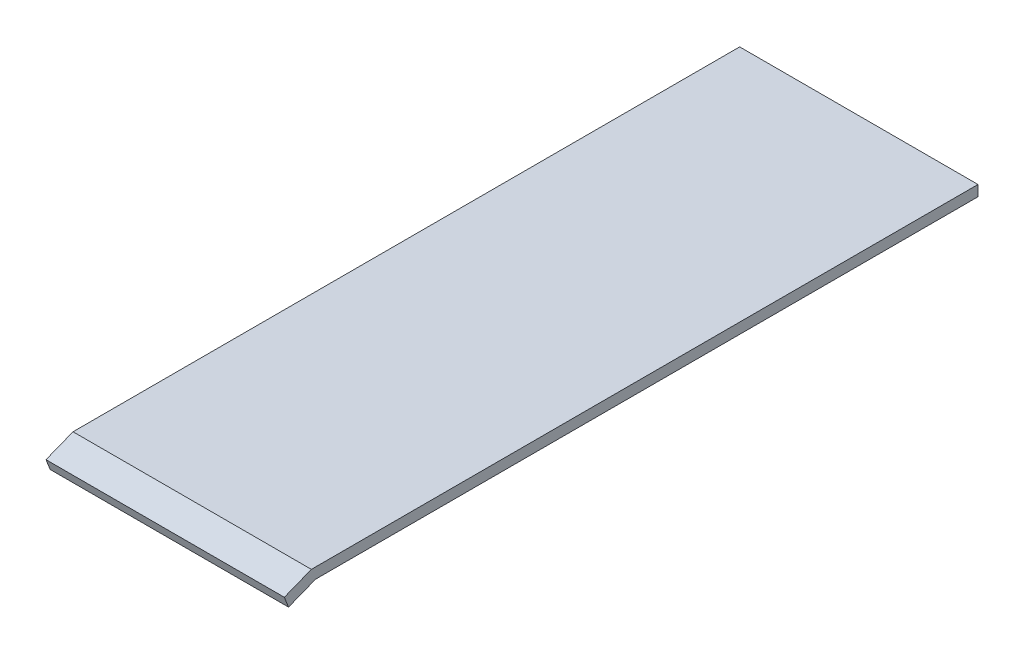
from build123d import *

# Parameters (mm, degrees)
SKETCH1_W                = 6.35
SKETCH1_H                = 6.35
BOSS_EXTRUDE1_DEPTH      = 5.08
BOSS_EXTRUDE2_DEPTH      = 14.850000018
BOSS_EXTRUDE2_DEPTH_BACK = 14.850000018


with BuildPart() as part:
    # Sketch1 → Boss-Extrude1 (new body)
    with BuildSketch(Plane(origin=(0, 0, 0), x_dir=(1, 0, 0), z_dir=(0, 1, 0))):
        Rectangle(SKETCH1_W, SKETCH1_H)
    extrude(amount=BOSS_EXTRUDE1_DEPTH)

    # Sketch2 → Boss-Extrude2 (add, two sides)
    with BuildSketch(Plane(origin=(3.175, 0, 0), x_dir=(0, 0, -1), z_dir=(1, 0, 0))) as boss_extrude2_sk:
        Polygon((3.175, 5.08), (-79.375, 5.08), (-82.741289638, 3.753009016), (-83.26438933, 5.08), (-79.898099692, 6.406990984), (3.175, 6.406990984), align=None)
    extrude(amount=BOSS_EXTRUDE2_DEPTH)
    extrude(boss_extrude2_sk.sketch, amount=-BOSS_EXTRUDE2_DEPTH_BACK)


solid = part.part
